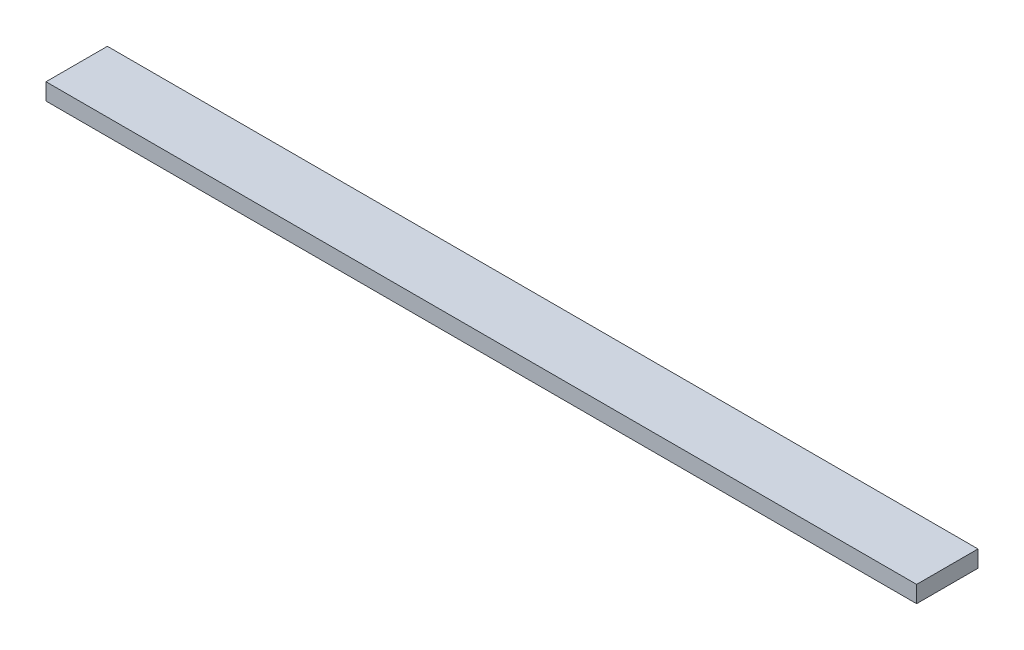
from build123d import *

# Parameters (mm, degrees)
SKETCH1_W           = 990.6
SKETCH1_H           = 69.85
BOSS_EXTRUDE1_DEPTH = 19.05


with BuildPart() as part:
    # Sketch1 → Boss-Extrude1 (new body)
    with BuildSketch(Plane(origin=(0, 0, 0), x_dir=(1, 0, 0), z_dir=(0, 1, 0))):
        with Locations((495.3, 34.925)):
            Rectangle(SKETCH1_W, SKETCH1_H)
    extrude(amount=BOSS_EXTRUDE1_DEPTH)


solid = part.part
